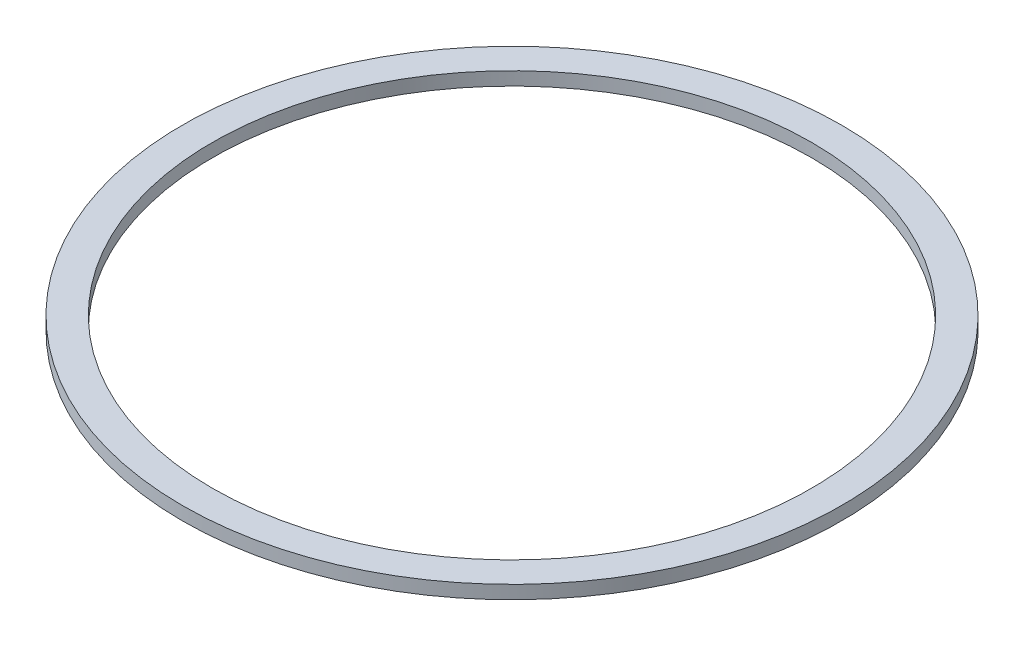
from build123d import *

# Parameters (mm, degrees)
ESBO_O1_R                = 99
ESBO_O1_R_2              = 90
RESSALTO_EXTRUS_O1_DEPTH = 4


with BuildPart() as part:
    # Esboço1 → Ressalto-extrusão1 (new body)
    with BuildSketch(Plane(origin=(0, 0, 0), x_dir=(1, 0, 0), z_dir=(0, 1, 0))):
        Circle(ESBO_O1_R)
        Circle(ESBO_O1_R_2, mode=Mode.SUBTRACT)
    extrude(amount=RESSALTO_EXTRUS_O1_DEPTH)


solid = part.part
